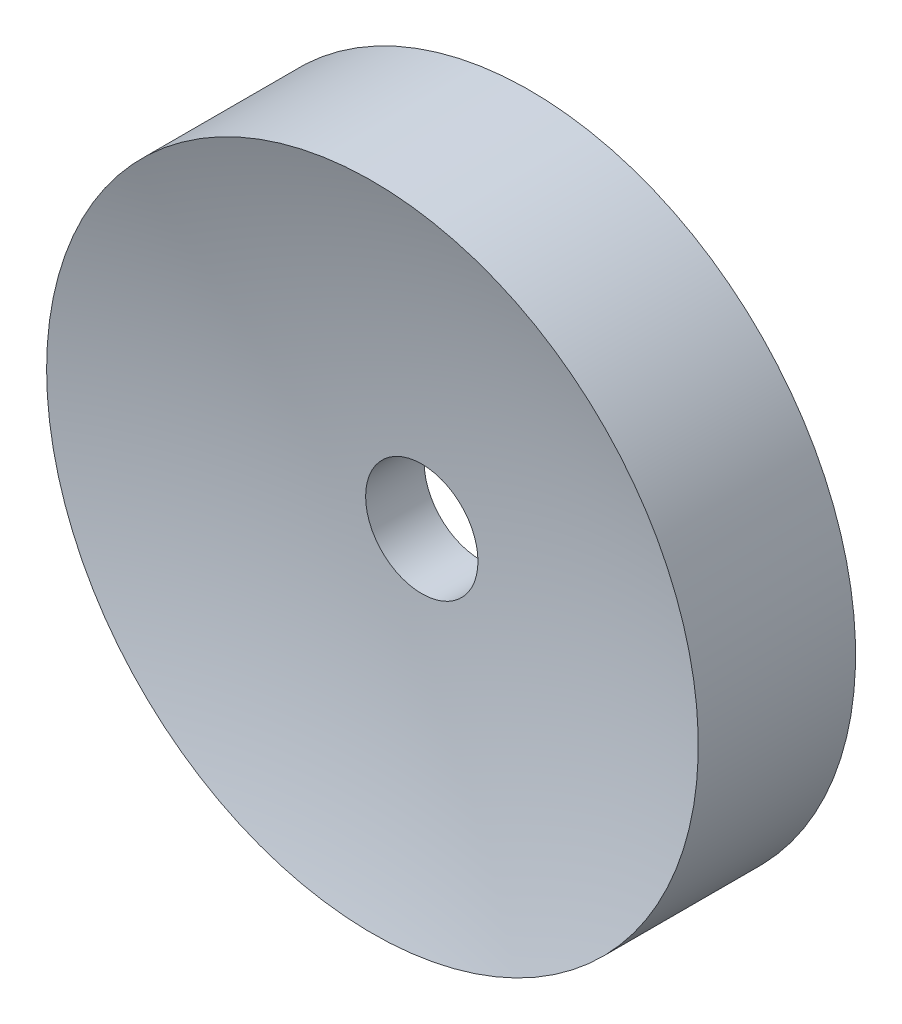
from build123d import *

# Parameters (mm, degrees)
SKETCH1_R           = 7.25
SKETCH1_R_2         = 1.25
BOSS_EXTRUDE1_DEPTH = 1.75


with BuildPart() as part:
    # Sketch1 → Boss-Extrude1 (new, symmetric)
    with BuildSketch(Plane.XY):
        Circle(SKETCH1_R)
        Circle(SKETCH1_R_2, mode=Mode.SUBTRACT)
    extrude(amount=BOSS_EXTRUDE1_DEPTH, both=True)

    # Sketch2 → Cut-Revolve1 (revolve, cut)
    with BuildSketch(Plane(origin=(0, 0, 0), x_dir=(1, 0, 0), z_dir=(0, 1, 0))):
        with BuildLine():
            Line((0, 1.75), (-7.25, 1.75))
            ThreePointArc((-7.250000000000001, 1.7499999999999964), (-3.668842228906902, 0.903465385674501), (3.5283e-13, 0.6190211308572593))
            Line((2e-16, 0.6190211308572557), (4e-16, 1.75))
        make_face()
    cut_revolve1 = revolve(axis=Axis((7.9e-16, 0, -3.982137231966947), (-1.8e-16, 0, 1)), mode=Mode.SUBTRACT)

    # Mirror1: Cut-Revolve1 across plane
    add(cut_revolve1.mirror(Plane.XY), mode=Mode.SUBTRACT)


solid = part.part
